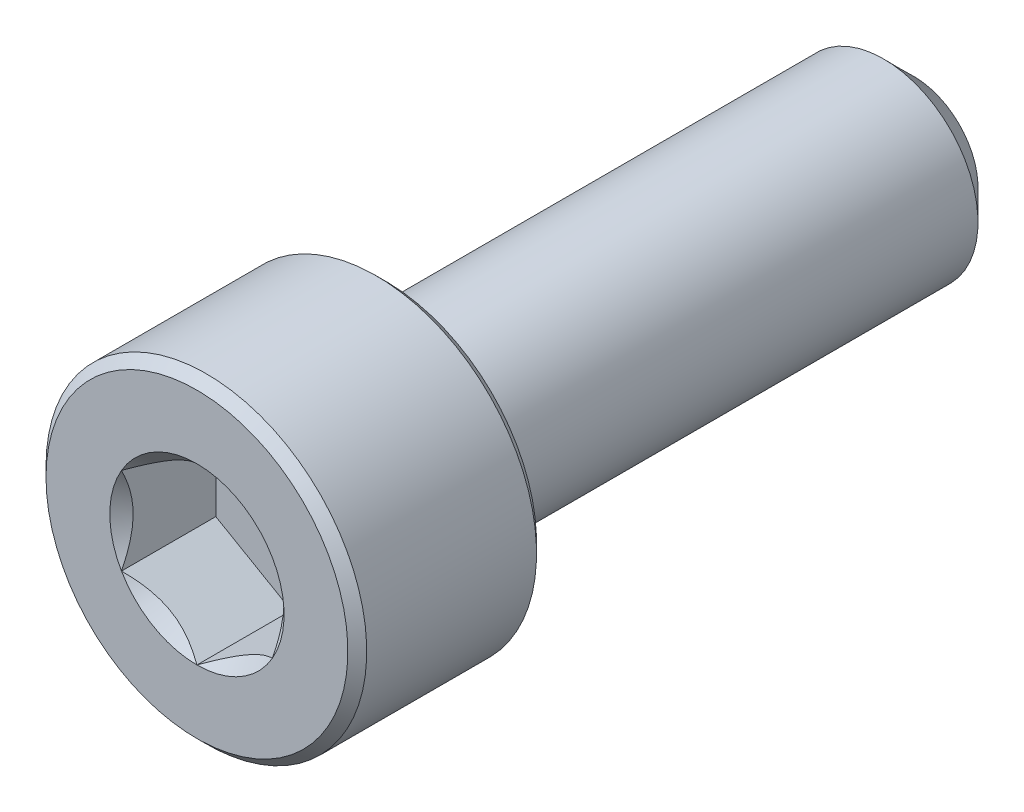
from build123d import *

# Parameters (mm, degrees)
CUT_EXTRUDE1_START = -2.5
CUT_EXTRUDE1_DEPTH = 2.5
SKETCH4_R          = 2.309401077
CUT_EXTRUDE2_DEPTH = 0.5
CUT_EXTRUDE2_TAPER = 45


with BuildPart() as part:
    # Sketch2 → Revolve1 (revolve)
    with BuildSketch(Plane(origin=(0, 0, 0), x_dir=(0, 0, -1), z_dir=(1, 0, 0))):
        Polygon((-9.25, 4.25), (-4.75, 4.25), (-4.5, 4), (-4.5, 2.5), (8.7, 2.5), (9.5, 1.7), (9.5, 0), (-9.5, 0), (-9.5, 4), align=None)
    revolve(axis=Axis((0, 0, -9.5), (0, 0, 1)))

    # Sketch3 → Cut-Extrude1 (cut)
    with BuildSketch(Plane.XY.offset(9.5).offset(CUT_EXTRUDE1_START)):
        Polygon((0, 2.309401077), (-2, 1.154700538), (-2, -1.154700538), (0, -2.309401077), (2, -1.154700538), (2, 1.154700538), align=None)
    extrude(amount=CUT_EXTRUDE1_DEPTH, mode=Mode.SUBTRACT)

    # Sketch4 → Cut-Extrude2 (cut)
    with BuildSketch(Plane.XY.offset(9.5)):
        Circle(SKETCH4_R)
    extrude(amount=-CUT_EXTRUDE2_DEPTH, taper=CUT_EXTRUDE2_TAPER, mode=Mode.SUBTRACT)


solid = part.part
